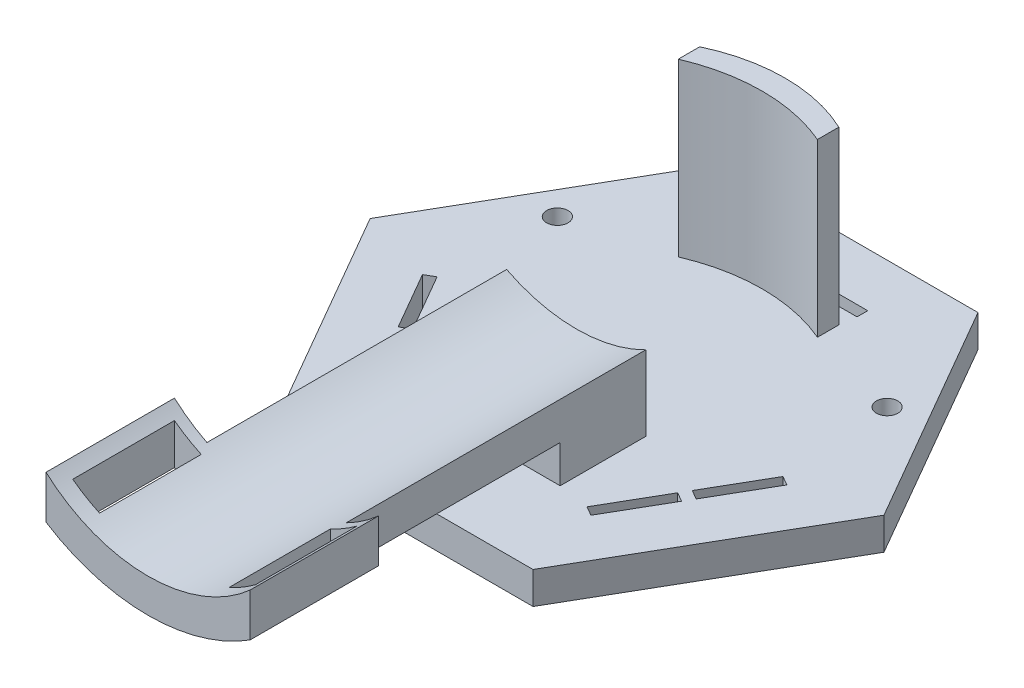
from build123d import *

# Parameters (mm, degrees)
EXTRUDE_1_DEPTH     = 3
SKETCH_4_W          = 13
SKETCH_4_H          = 8
EXTRUDE_2_DEPTH     = 7
EXTRUDE_6_DEPTH     = 20
CUT_EXTRUDE_3_DEPTH = 34.531337759
EXTRUDE_7_DEPTH     = 16
SKETCH_18_W         = 6.2
SKETCH_18_H         = 1
CUT_EXTRUDE_6_DEPTH = 20
SKETCH_19_R         = 1
CUT_EXTRUDE_7_DEPTH = 3
EXTRUDE_8_DEPTH     = 12
SKETCH_24_W         = 2.5
SKETCH_24_H         = 9.5
CUT_EXTRUDE_8_DEPTH = 20
SKETCH_25_W         = 5
SKETCH_25_H         = 5.2
CUT_EXTRUDE_9_DEPTH = 1


with BuildPart() as part:
    # 草图1 → 凸台-拉伸1 (new body)
    with BuildSketch(Plane(origin=(0, 0, 0), x_dir=(1, 0, 0), z_dir=(0, 1, 0))):
        Polygon((24, 0), (12, 20.784609691), (-12, 20.784609691), (-24, 0), (-12, -20.784609691), (12, -20.784609691), align=None)
    extrude(amount=EXTRUDE_1_DEPTH)

    # 草图4 → 凸台-拉伸2 (add)
    with BuildSketch(Plane(origin=(0, 3, 0), x_dir=(1, 0, 0), z_dir=(0, 1, 0))):
        with Locations((0, -8.746728068)):
            Rectangle(SKETCH_4_W, SKETCH_4_H)
    extrude(amount=EXTRUDE_2_DEPTH)

    # 草图14 → 凸台-拉伸6 (add)
    with BuildSketch(Plane.XY.offset(12.746728068)):
        with BuildLine():
            Line((-6.5, 10), (-6.5, 6.5))
            ThreePointArc((-6.5, 6.5), (0, 5.267826192), (6.5, 6.5))
            Line((6.5, 6.5), (6.5, 10))
            ThreePointArc((6.5, 10), (0, 8.436464997), (-6.5, 10))
        make_face()
    extrude(amount=EXTRUDE_6_DEPTH)

    # 草图15 → 切除-拉伸3 (cut, through all)
    with BuildSketch(Plane.XY.offset(12.746728068)):
        with BuildLine():
            Line((6.5, 10), (-6.5, 10))
            ThreePointArc((-6.5, 10), (0, 8.436464997), (6.5, 10))
        make_face()
    extrude(amount=-CUT_EXTRUDE_3_DEPTH, mode=Mode.SUBTRACT)

    # 草图16 → 凸台-拉伸7 (add)
    with BuildSketch(Plane(origin=(0, 3, 0), x_dir=(1, 0, 0), z_dir=(0, 1, 0))):
        with BuildLine():
            Line((6.5, 13.284609691), (6.5, 11.284609691))
            ThreePointArc((6.5, 11.284609691), (0, 12.623387741), (-6.5, 11.284609691))
            Line((-6.5, 11.284609691), (-6.5, 13.284609691))
            ThreePointArc((-6.5, 13.284609691), (0, 14.747919911), (6.5, 13.284609691))
        make_face()
    extrude(amount=EXTRUDE_7_DEPTH)

    # 草图18 → 切除-拉伸6 (cut, through all)
    with BuildSketch(Plane.XZ):
        Polygon((10.319872981, 13.694675051), (9.453847577, 13.194675051), (12.553847577, 7.825317547), (13.419872981, 8.325317547), align=None)
        Polygon((13.053847577, 6.959292144), (13.919872981, 7.459292144), (17.019872981, 2.08993464), (16.153847577, 1.58993464), align=None)
        with Locations((3.6, -15.284609691)):
            Rectangle(SKETCH_18_W, SKETCH_18_H)
        with Locations((-3.6, -15.284609691)):
            Rectangle(SKETCH_18_W, SKETCH_18_H)
        Polygon((-16.153847577, 1.58993464), (-13.053847577, 6.959292144), (-13.919872981, 7.459292144), (-17.019872981, 2.08993464), align=None)
        Polygon((-12.553847577, 7.825317547), (-13.419872981, 8.325317547), (-10.319872981, 13.694675051), (-9.453847577, 13.194675051), align=None)
    extrude(amount=-CUT_EXTRUDE_6_DEPTH, mode=Mode.SUBTRACT)

    # 草图19 → 切除-拉伸7 (cut)
    with BuildSketch(Plane.XZ):
        with Locations((0, 17.784609691)):
            Circle(SKETCH_19_R)
        with Locations((15.401923789, -8.892304845)):
            Circle(SKETCH_19_R)
        with Locations((-15.401923789, -8.892304845)):
            Circle(SKETCH_19_R)
    extrude(amount=-CUT_EXTRUDE_7_DEPTH, mode=Mode.SUBTRACT)

    # 草图23 → 凸台-拉伸8 (add)
    with BuildSketch(Plane.XY.offset(32.746728068)):
        with BuildLine():
            Line((-9.532090727, 12.079217693), (-9.532090727, 8.042497168))
            ThreePointArc((-9.532090727, 8.042497168), (0, 5.267826192), (9.532090727, 8.042497168))
            Line((9.532090727, 8.042497168), (9.532090727, 12.079217693))
            ThreePointArc((9.532090727, 12.079217693), (0, 8.436464997), (-9.532090727, 12.079217693))
        make_face()
    extrude(amount=EXTRUDE_8_DEPTH)

    # 草图24 → 切除-拉伸8 (cut, through all)
    with BuildSketch(Plane.XZ):
        with Locations((-7.282090727, 38.496728068)):
            Rectangle(SKETCH_24_W, SKETCH_24_H)
        with Locations((7.282090727, 38.496728068)):
            Rectangle(SKETCH_24_W, SKETCH_24_H)
    extrude(amount=-CUT_EXTRUDE_8_DEPTH, mode=Mode.SUBTRACT)

    # 草图25 → 切除-拉伸9 (cut)
    with BuildSketch(Plane.XZ):
        Polygon((-10.532695155, -0.673943767), (-6.029363055, -3.273943767), (-3.529363055, 1.056183252), (-8.032695155, 3.656183252), align=None)
        Polygon((-7.182695155, 5.128426439), (-4.682695155, 9.458553458), (-0.179363055, 6.858553458), (-2.679363055, 2.528426439), align=None)
        Polygon((6.029363055, -3.273943767), (3.529363055, 1.056183252), (8.032695155, 3.656183252), (10.532695155, -0.673943767), align=None)
        Polygon((0.179363055, 6.858553458), (2.679363055, 2.528426439), (7.182695155, 5.128426439), (4.682695155, 9.458553458), align=None)
        with Locations((-3.35, -6.184609691)):
            Rectangle(SKETCH_25_W, SKETCH_25_H)
        with Locations((3.35, -6.184609691)):
            Rectangle(SKETCH_25_W, SKETCH_25_H)
    extrude(amount=-CUT_EXTRUDE_9_DEPTH, mode=Mode.SUBTRACT)


solid = part.part
